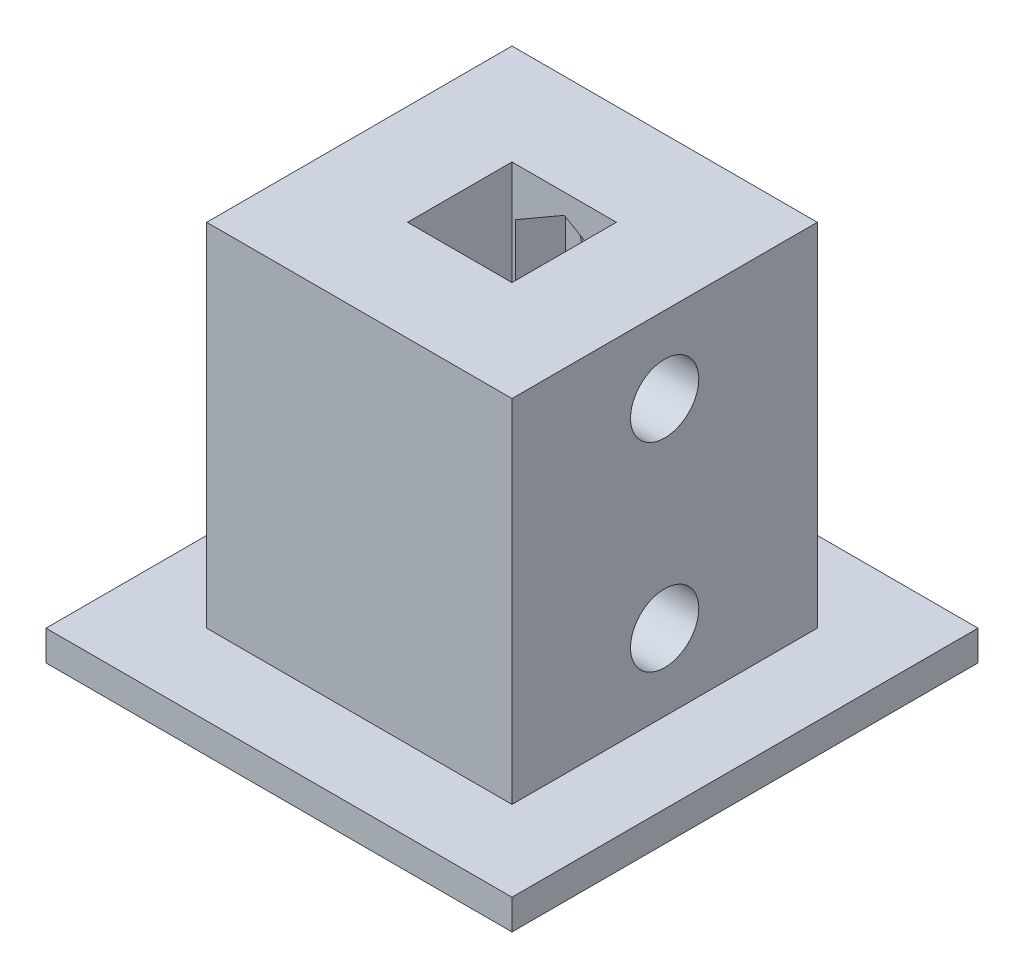
from build123d import *

# Parameters (mm, degrees)
SKETCH1_W           = 30.4
SKETCH1_H           = 30.4
SKETCH1_W_2         = 10.4
SKETCH1_H_2         = 10.4
BOSS_EXTRUDE1_DEPTH = 35
CUT_EXTRUDE1_DEPTH  = 5
SKETCH3_R           = 3.4
CUT_EXTRUDE2_DEPTH  = 6
BOSS_EXTRUDE3_DEPTH = 10.4
BOSS_EXTRUDE4_DEPTH = 10.4
CUT_EXTRUDE3_DEPTH  = 5
SKETCH8_R           = 3.4
CUT_EXTRUDE4_DEPTH  = 6
SKETCH9_W           = 46.4
SKETCH9_H           = 46.4
SKETCH9_W_2         = 10.4
SKETCH9_H_2         = 10.4
BOSS_EXTRUDE7_DEPTH = 3


with BuildPart() as part:
    # Sketch1 → Boss-Extrude1 (new body)
    with BuildSketch(Plane(origin=(0, 0, 0), x_dir=(1, 0, 0), z_dir=(0, 1, 0))):
        with Locations((5.2, 5.2)):
            Rectangle(SKETCH1_W, SKETCH1_H)
        with Locations((5.2, 5.2)):
            Rectangle(SKETCH1_W_2, SKETCH1_H_2, mode=Mode.SUBTRACT)
    extrude(amount=BOSS_EXTRUDE1_DEPTH)

    # Sketch2 → Cut-Extrude1 (cut)
    with BuildSketch(Plane.ZY.offset(-10.4)):
        Polygon((-5.2, 33), (-10.049742261, 30.2), (-10.049742261, 24.6), (-5.2, 21.8), (-0.350257739, 24.6), (-0.350257739, 30.2), align=None)
        Polygon((-0.350257739, 10.4), (-0.350257739, 4.8), (-5.2, 2), (-10.049742261, 4.8), (-10.049742261, 10.4), (-5.2, 13.2), align=None)
    extrude(amount=-CUT_EXTRUDE1_DEPTH, mode=Mode.SUBTRACT)

    # Sketch3 → Cut-Extrude2 (cut, through all)
    with BuildSketch(Plane.ZY.offset(-15.4)):
        with Locations((-5.2, 27.4)):
            Circle(SKETCH3_R)
        with Locations((-5.2, 7.6)):
            Circle(SKETCH3_R)
    extrude(amount=-CUT_EXTRUDE2_DEPTH, mode=Mode.SUBTRACT)

    # Sketch4 → Boss-Extrude3 (add)
    with BuildSketch(Plane.ZY.offset(-10.4)):
        with BuildLine():
            Line((0, 22.5), (0, 12.5))
            add(Edge.make_bspline(
                [(0, 22.5), (-2.112225074, 21.952514627), (-1.887774926, 17.5), (-2.112225074, 13.047485373), (0, 12.5)],
                knots=[0, 0, 0, 0, 0.5, 1, 1, 1, 1], degree=3))
        make_face()
    extrude(amount=BOSS_EXTRUDE3_DEPTH)

    # Sketch6 → Boss-Extrude4 (add)
    with BuildSketch(Plane.XY.offset(-10.4)):
        with BuildLine():
            Line((0, 12.5), (0, 22.5))
            add(Edge.make_bspline(
                [(0, 12.5), (2.112225074, 13.047485373), (1.887774926, 17.5), (2.112225074, 21.952514627), (0, 22.5)],
                knots=[0, 0, 0, 0, 0.5, 1, 1, 1, 1], degree=3))
        make_face()
    extrude(amount=BOSS_EXTRUDE4_DEPTH)

    # Sketch7 → Cut-Extrude3 (cut)
    with BuildSketch(Plane.XY.offset(-10.4)):
        Polygon((10.049742261, 24.6), (10.049742261, 30.2), (5.2, 33), (0.350257739, 30.2), (0.350257739, 24.6), (5.2, 21.8), align=None)
        Polygon((10.049742261, 4.8), (5.2, 2), (0.350257739, 4.8), (0.350257739, 10.4), (5.2, 13.2), (10.049742261, 10.4), align=None)
    extrude(amount=-CUT_EXTRUDE3_DEPTH, mode=Mode.SUBTRACT)

    # Sketch8 → Cut-Extrude4 (cut, through all)
    with BuildSketch(Plane.XY.offset(-15.4)):
        with Locations((5.2, 27.4)):
            Circle(SKETCH8_R)
        with Locations((5.2, 7.6)):
            Circle(SKETCH8_R)
    extrude(amount=-CUT_EXTRUDE4_DEPTH, mode=Mode.SUBTRACT)

    # Sketch9 → Boss-Extrude7 (add)
    with BuildSketch(Plane.XZ):
        with Locations((5.2, -5.2)):
            Rectangle(SKETCH9_W, SKETCH9_H)
        with Locations((5.2, -5.2)):
            Rectangle(SKETCH9_W_2, SKETCH9_H_2, mode=Mode.SUBTRACT)
    extrude(amount=BOSS_EXTRUDE7_DEPTH)


solid = part.part
